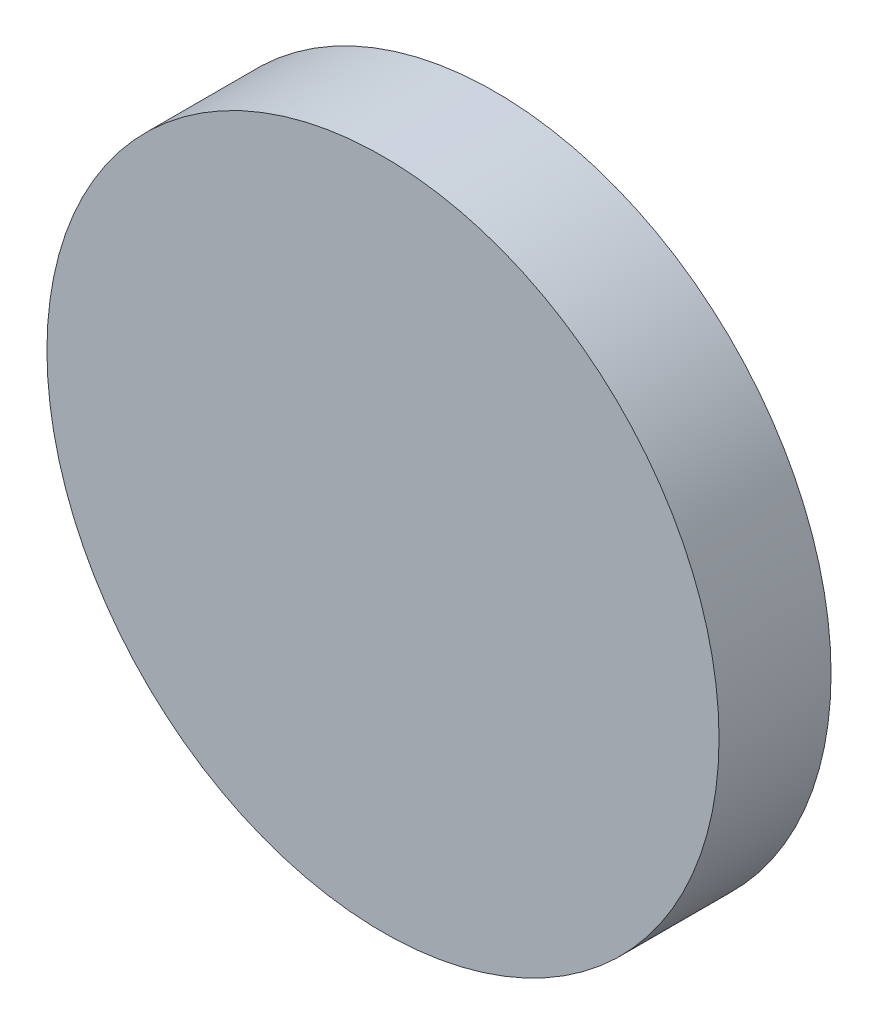
from build123d import *

# Parameters (mm, degrees)
SKETCH1_R           = 3
BOSS_EXTRUDE1_DEPTH = 1


with BuildPart() as part:
    # Sketch1 → Boss-Extrude1 (new body)
    with BuildSketch(Plane.XY):
        Circle(SKETCH1_R)
    extrude(amount=BOSS_EXTRUDE1_DEPTH)


solid = part.part
